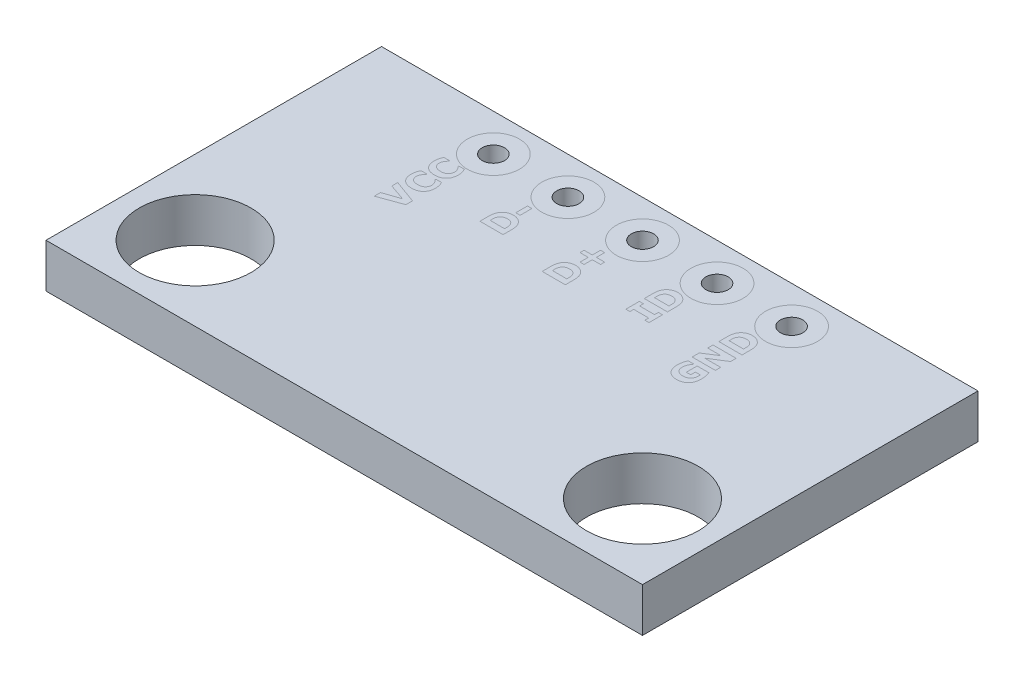
from build123d import *

# Parameters (mm, degrees)
SKETCH_1_W      = 20.32
SKETCH_1_H      = 11.43
SKETCH_1_R      = 1.905
SKETCH_1_R_2    = 0.381
EXTRUDE_1_DEPTH = 1.5


with BuildPart() as part:
    # 스케치1 → 보스-돌출1 (new body)
    with BuildSketch(Plane(origin=(0, 0, 0), x_dir=(1, 0, 0), z_dir=(0, 1, 0))):
        Rectangle(SKETCH_1_W, SKETCH_1_H)
        with Locations((-7.62, -3.175)):
            Circle(SKETCH_1_R, mode=Mode.SUBTRACT)
        with Locations((7.62, -3.175)):
            Circle(SKETCH_1_R, mode=Mode.SUBTRACT)
        with Locations((5.08, 4.445)):
            Circle(SKETCH_1_R_2, mode=Mode.SUBTRACT)
        with Locations((2.54, 4.445)):
            Circle(SKETCH_1_R_2, mode=Mode.SUBTRACT)
        with Locations((-2.54, 4.445)):
            Circle(SKETCH_1_R_2, mode=Mode.SUBTRACT)
        with Locations((-5.08, 4.445)):
            Circle(SKETCH_1_R_2, mode=Mode.SUBTRACT)
        with Locations((0, 4.445)):
            Circle(SKETCH_1_R_2, mode=Mode.SUBTRACT)
    extrude(amount=EXTRUDE_1_DEPTH)


solid = part.part
